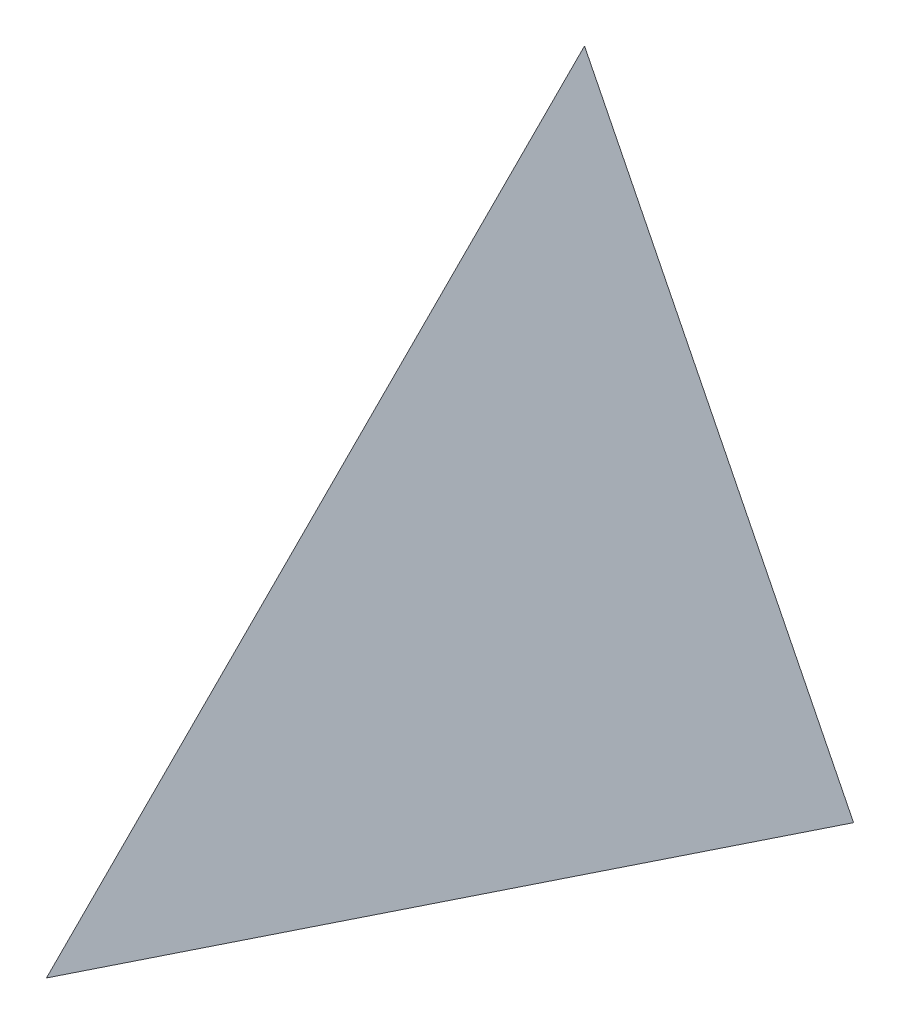
from build123d import *

# Parameters (mm, degrees)
SKETCH1_W           = 4
SKETCH1_H           = 4
BOSS_EXTRUDE1_DEPTH = 4
CUT_EXTRUDE1_DEPTH  = 10
CUT_EXTRUDE2_DEPTH  = 10


with BuildPart() as part:
    # Sketch1 → Boss-Extrude1 (new body)
    with BuildSketch(Plane(origin=(0, 0, 0), x_dir=(1, 0, 0), z_dir=(0, 1, 0))):
        Rectangle(SKETCH1_W, SKETCH1_H)
    extrude(amount=BOSS_EXTRUDE1_DEPTH)

    # 3DSketch1 → Cut-Extrude1 (cut, along a direction that is not the sketch's normal)
    with BuildSketch(Plane(origin=(0, 4, -2), x_dir=(0, -0.7071067811865476, 0.7071067811865476), z_dir=(0.816496580927726, -0.408248290463863, -0.408248290463863))):
        Polygon((0, 0), (2.828427125, 3.464101615), (5.656854249, 0), align=None)
    extrude(amount=-CUT_EXTRUDE1_DEPTH, dir=(0, -1, 0), mode=Mode.SUBTRACT)


with BuildPart() as body_2:
    # of the pieces the cut leaves, the one that is kept (cut_extrude1_keep)
    add(part.part.solids().sort_by_distance((2, 0, 2))[0])

    # 3DSketch2 → Cut-Extrude2 (cut, along a direction that is not the sketch's normal)
    with BuildSketch(Plane(origin=(0, 4, -2), x_dir=(0, -0.7071067811865475, 0.7071067811865476), z_dir=(0.816496580927726, 0.40824829046386313, 0.408248290463863))):
        Polygon((0, 0), (5.656854249, 0), (2.828427125, 3.464101615), align=None)
    extrude(amount=CUT_EXTRUDE2_DEPTH, dir=(0, 1, 0), mode=Mode.SUBTRACT)


with BuildPart() as body_2_2:
    # of the pieces the cut leaves, the one that is kept (cut_extrude2_keep)
    add(body_2.part.solids().sort_by_distance((-2, 0, -2))[0])


solid = body_2_2.part
